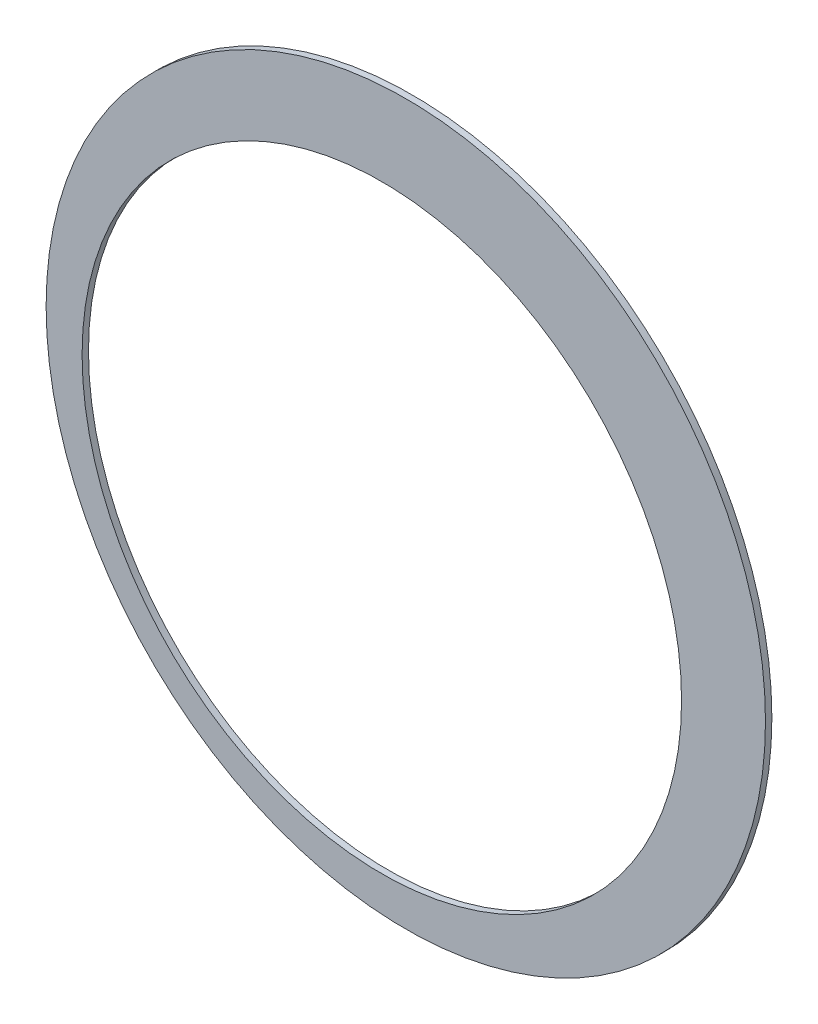
from build123d import *

# Parameters (mm, degrees)
SKETCH2_R          = 45
BASE_EXTRUDE_DEPTH = 0.8
SKETCH3_R          = 37.5
CUT_EXTRUDE5_DEPTH = 1.8


with BuildPart() as part:
    # Sketch2 → Base-Extrude (new body)
    with BuildSketch(Plane.XY):
        with Locations((3, 3)):
            Circle(SKETCH2_R)
    extrude(amount=BASE_EXTRUDE_DEPTH)

    # Sketch3 → Cut-Extrude5 (cut, through all)
    with BuildSketch(Plane.XY):
        Circle(SKETCH3_R)
    extrude(amount=CUT_EXTRUDE5_DEPTH, mode=Mode.SUBTRACT)


solid = part.part
